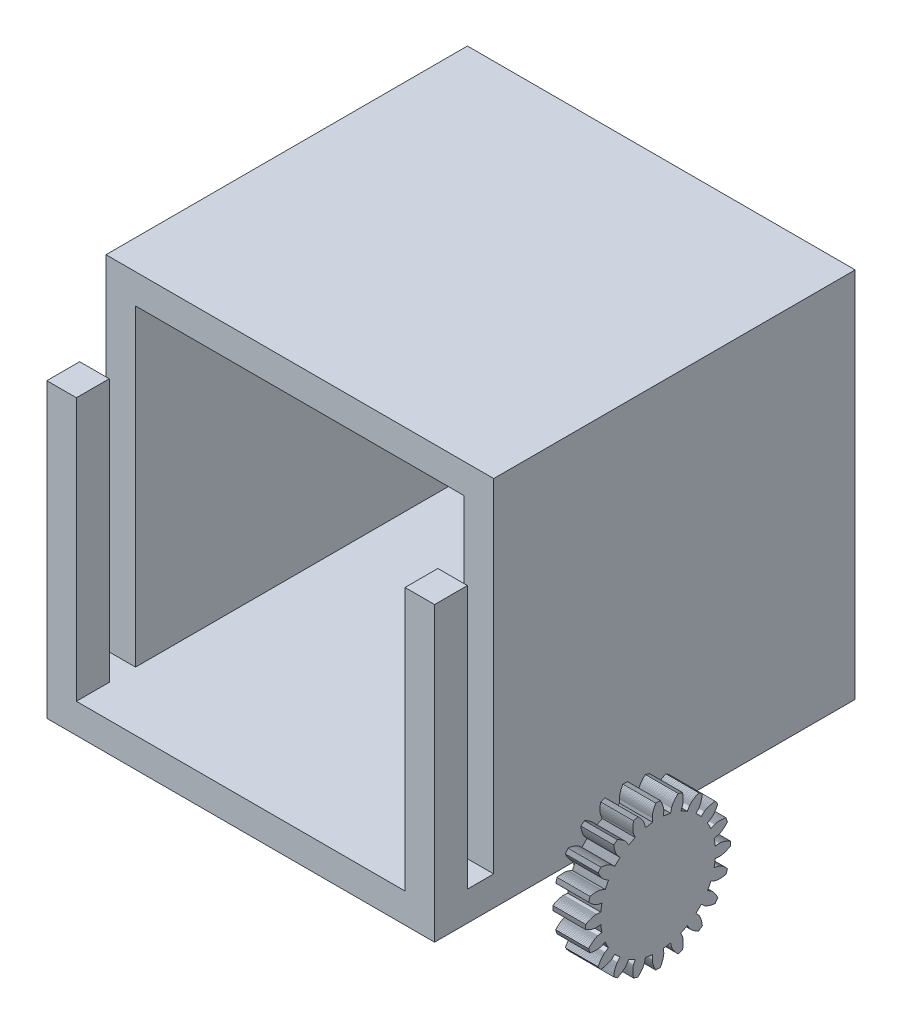
from build123d import *

# Parameters (mm, degrees)
SKETCH1_W           = 59
SKETCH1_H           = 56.6
SKETCH1_W_2         = 50
SKETCH1_H_2         = 47.6
BOSS_EXTRUDE1_DEPTH = 3
BOSS_EXTRUDE2_START = 3
SKETCH1_3_W         = 59
SKETCH1_3_H         = 56.6
SKETCH1_3_W_2       = 50
SKETCH1_3_H_2       = 47.6
BOSS_EXTRUDE2_DEPTH = 52
SKETCH2_W           = 59
SKETCH2_H           = 4.5
BOSS_EXTRUDE3_DEPTH = 4
BOSS_EXTRUDE4_DEPTH = 5
SKETCH4_R           = 1.75
BOSS_EXTRUDE5_DEPTH = 10
BOSS_EXTRUDE6_DEPTH = 5
BOSS_EXTRUDE8_START = 35
BOSS_EXTRUDE8_DEPTH = 3


with BuildPart() as part:
    # Sketch1 → Boss-Extrude1 (new body)
    with BuildSketch(Plane.XY):
        Rectangle(SKETCH1_W, SKETCH1_H)
        Rectangle(SKETCH1_W_2, SKETCH1_H_2, mode=Mode.SUBTRACT)
        Rectangle(SKETCH1_W_2, SKETCH1_H_2)
    extrude(amount=BOSS_EXTRUDE1_DEPTH)

    # Sketch1_3 → Boss-Extrude2 (add)
    with BuildSketch(Plane.XY.offset(BOSS_EXTRUDE2_START)):
        Rectangle(SKETCH1_3_W, SKETCH1_3_H)
        Rectangle(SKETCH1_3_W_2, SKETCH1_3_H_2, mode=Mode.SUBTRACT)
    extrude(amount=BOSS_EXTRUDE2_DEPTH)

    # Sketch2 → Boss-Extrude3 (add)
    with BuildSketch(Plane.XY.offset(55)):
        with Locations((0, -26.05)):
            Rectangle(SKETCH2_W, SKETCH2_H)
    extrude(amount=BOSS_EXTRUDE3_DEPTH)

    # Sketch3 → Boss-Extrude4 (add)
    with BuildSketch(Plane.XY.offset(59)):
        Polygon((-29.5, -28.3), (-29.5, 16.2), (-25, 16.2), (-25, -23.8), (25, -23.8), (25, 16.2), (29.5, 16.2), (29.5, -28.3), align=None)
    extrude(amount=BOSS_EXTRUDE4_DEPTH)

    # Sketch4 → Boss-Extrude5 (add, symmetric)
    with BuildSketch(Plane(origin=(0, -28.3, 0), x_dir=(0, -1, 0), z_dir=(-1, 0, 0))):
        with BuildLine():
            Line((1.895041041, 41.1411879), (6.249518351, 39.416071279))
            ThreePointArc((6.249518351, 39.416071279), (9.25, 35), (6.249518351, 30.583928721))
            Line((6.249518351, 30.583928721), (1.895041041, 28.8588121))
            ThreePointArc((1.895041041, 28.8588121), (0.518581366, 27.755704237), (0, 26.06971445))
            Line((0, 26.06971445), (0, 43.93028555))
            ThreePointArc((0, 43.93028555), (0.518581366, 42.244295763), (1.895041041, 41.1411879))
        make_face()
        with Locations((4.5, 35)):
            Circle(SKETCH4_R, mode=Mode.SUBTRACT)
    extrude(amount=BOSS_EXTRUDE5_DEPTH, both=True)

    # Sketch6 → Boss-Extrude6 (add)
    with BuildSketch(Plane(origin=(29.5, 0, 0), x_dir=(0, 0, -1), z_dir=(1, 0, 0))):
        Polygon((-26.2881519, -33.6164474), (-25.6440481, -33.6768109), (-25.6392413, -33.6771581), (-25.6247974, -33.6777886), (-25.6007031, -33.6780851), (-25.5669749, -33.6774303), (-25.5236589, -33.6752074), (-25.4708308, -33.6708025), (-25.4085958, -33.6636047), (-25.3370884, -33.6530082), (-25.2564722, -33.6384133), (-25.1669396, -33.6192276), (-25.0687116, -33.594867), (-24.9620375, -33.5647573), (-24.8471942, -33.5283355), (-24.7244859, -33.4850503), (-24.5942437, -33.434364), (-24.4568251, -33.3757533), (-24.3126129, -33.3087105), (-24.1620153, -33.2327446), (-24.0054646, -33.1473822), (-24.0043704, -33.110826), (-24.0033977, -33.0742663), (-24.0025466, -33.0377036), (-24.0018171, -33.0011383), (-24.0012091, -32.9645707), (-24.0007228, -32.9280013), (-24.000358, -32.8914305), (-24.0001148, -32.8548587), (-23.999949202, -32.805053205), (-23.999949202, -32.794946795), (-24.0001148, -32.7451413), (-24.000358, -32.7085695), (-24.0007228, -32.6719987), (-24.0012091, -32.6354293), (-24.0018171, -32.5988617), (-24.0025466, -32.5622964), (-24.0033977, -32.5257337), (-24.0043704, -32.489174), (-24.0054646, -32.4526178), (-24.1620153, -32.3672554), (-24.3126129, -32.2912895), (-24.4568251, -32.2242467), (-24.5942437, -32.165636), (-24.7244859, -32.1149497), (-24.8471942, -32.0716645), (-24.9620375, -32.0352427), (-25.0687116, -32.005133), (-25.1669396, -31.9807724), (-25.2564722, -31.9615867), (-25.3370884, -31.9469918), (-25.4085958, -31.9363953), (-25.4708308, -31.9291975), (-25.5236589, -31.9247926), (-25.5669749, -31.9225697), (-25.6007031, -31.9219149), (-25.6247974, -31.9222114), (-25.6392413, -31.9228419), (-25.6440481, -31.9231891), (-26.2881519, -31.9835526), (-26.2938163, -31.9252155), (-26.2998713, -31.8669176), (-26.3063166, -31.8086616), (-26.3131521, -31.7504501), (-26.3203773, -31.6922857), (-26.3279919, -31.634171), (-26.3359957, -31.5761085), (-26.3443882, -31.518101), (-26.3531691, -31.460151), (-26.3623379, -31.4022612), (-26.3718943, -31.344434), (-26.3818379, -31.2866722), (-26.3921681, -31.2289782), (-26.4028846, -31.1713548), (-26.4139868, -31.1138044), (-26.4254743, -31.0563297), (-26.4373465, -30.9989332), (-26.4496029, -30.9416176), (-26.4622429, -30.8843853), (-25.8310104, -30.7427554), (-25.8263316, -30.7416002), (-25.8123998, -30.7377364), (-25.7893931, -30.7305729), (-25.7575181, -30.7195275), (-25.717009, -30.7040281), (-25.6681277, -30.6835139), (-25.611163, -30.6574368), (-25.5464299, -30.6252619), (-25.4742693, -30.5864696), (-25.3950475, -30.5405557), (-25.309155, -30.4870333), (-25.2170063, -30.4254332), (-25.1190387, -30.3553054), (-25.0157121, -30.2762198), (-24.9075074, -30.1877673), (-24.7949261, -30.0895605), (-24.6784896, -29.981235), (-24.5587375, -29.8624499), (-24.4362273, -29.7328886), (-24.4464832, -29.6977835), (-24.4568557, -29.6627126), (-24.4673448, -29.6276764), (-24.4779503, -29.5926752), (-24.4886721, -29.5577095), (-24.4995101, -29.5227797), (-24.5104641, -29.4878861), (-24.5215341, -29.4530291), (-24.53272, -29.4182091), (-24.5440216, -29.3834264), (-24.5554387, -29.3486816), (-24.5669713, -29.3139749), (-24.5786192, -29.2793067), (-24.5903823, -29.2446775), (-24.6022605, -29.2100875), (-24.6142537, -29.1755373), (-24.6263616, -29.1410271), (-24.6385842, -29.1065573), (-24.6509214, -29.0721284), (-24.8261883, -29.0393208), (-24.99289, -29.0136101), (-25.1507612, -28.9944126), (-25.2995659, -28.9811353), (-25.4390964, -28.9731768), (-25.5691748, -28.9699291), (-25.6896523, -28.9707784), (-25.8004098, -28.9751065), (-25.901358, -28.9822923), (-25.9924373, -28.9917126), (-26.0736179, -29.0027439), (-26.1449, -29.0147631), (-26.2063133, -29.0271492), (-26.257917, -29.0392846), (-26.2997998, -29.050556), (-26.3320796, -29.0603557), (-26.354903, -29.0680833), (-26.3684451, -29.0731464), (-26.3729094, -29.0749619), (-26.9668351, -29.3314101), (-26.9902494, -29.2776786), (-27.0140231, -29.2241051), (-27.0381551, -29.1706921), (-27.0626443, -29.1174419), (-27.0874897, -29.0643569), (-27.1126901, -29.0114396), (-27.1382444, -28.9586923), (-27.1641515, -28.9061173), (-27.1904101, -28.853717), (-27.2170192, -28.8014938), (-27.2439774, -28.74945), (-27.2712837, -28.697588), (-27.2989368, -28.64591), (-27.3269354, -28.5944184), (-27.3552782, -28.5431155), (-27.3839641, -28.4920036), (-27.4129917, -28.441085), (-27.4423598, -28.390362), (-27.4720669, -28.3398369), (-26.9154952, -28.0100773), (-26.9114024, -28.0075328), (-26.8993464, -27.999553), (-26.8796794, -27.9856306), (-26.8527776, -27.9652759), (-26.8190408, -27.9380171), (-26.7788912, -27.9034018), (-26.7327728, -27.8609979), (-26.6811505, -27.8103941), (-26.6245092, -27.7512016), (-26.5633529, -27.6830541), (-26.4982037, -27.605609), (-26.4296005, -27.5185483), (-26.3580985, -27.4215792), (-26.2842678, -27.3144346), (-26.2086923, -27.1968741), (-26.1319688, -27.0686844), (-26.0547055, -26.9296799), (-25.9775211, -26.7797031), (-25.9010436, -26.6186253), (-25.9216456, -26.5884075), (-25.942348, -26.5582584), (-25.9631504, -26.5281783), (-25.9840528, -26.4981675), (-26.0050548, -26.4682264), (-26.0261563, -26.4383552), (-26.047357, -26.4085544), (-26.0686566, -26.3788243), (-26.0900549, -26.3491651), (-26.1115518, -26.3195772), (-26.1331469, -26.290061), (-26.15484, -26.2606167), (-26.1766309, -26.2312447), (-26.1985193, -26.2019454), (-26.220505, -26.1727189), (-26.2425878, -26.1435658), (-26.2647674, -26.1144862), (-26.2870435, -26.0854805), (-26.3094159, -26.056549), (-26.4862428, -26.0795076), (-26.6527305, -26.1065689), (-26.8088074, -26.137096), (-26.9544319, -26.1704516), (-27.0895927, -26.206), (-27.2143082, -26.2431076), (-27.3286266, -26.2811449), (-27.4326258, -26.3194872), (-27.5264127, -26.357516), (-27.6101232, -26.3946203), (-27.6839218, -26.4301979), (-27.7480009, -26.4636562), (-27.8025809, -26.4944138), (-27.8479089, -26.5219017), (-27.8842588, -26.5455639), (-27.9119304, -26.564859), (-27.9312487, -26.5792612), (-27.9425635, -26.5882612), (-27.9462482, -26.5913674), (-28.4318584, -27.0187973), (-28.4707306, -26.974931), (-28.5098958, -26.9313261), (-28.5493523, -26.8879845), (-28.5890981, -26.8449081), (-28.6291316, -26.802099), (-28.669451, -26.759559), (-28.7100544, -26.71729), (-28.7509401, -26.6752939), (-28.7921061, -26.6335727), (-28.8335507, -26.5921281), (-28.8752719, -26.5509621), (-28.917268, -26.5100764), (-28.959537, -26.469473), (-29.002077, -26.4291536), (-29.0448861, -26.3891201), (-29.0879625, -26.3493743), (-29.1313041, -26.3099178), (-29.174909, -26.2707526), (-29.2187753, -26.2318804), (-28.7913454, -25.7462702), (-28.7882392, -25.7425855), (-28.7792392, -25.7312707), (-28.764837, -25.7119524), (-28.7455419, -25.6842808), (-28.7218797, -25.6479309), (-28.6943918, -25.6026029), (-28.6636342, -25.5480229), (-28.6301759, -25.4839438), (-28.5945983, -25.4101452), (-28.557494, -25.3264347), (-28.5194652, -25.2326478), (-28.4811229, -25.1286486), (-28.4430856, -25.0143302), (-28.405978, -24.8896147), (-28.3704296, -24.7544539), (-28.337074, -24.6088294), (-28.3065469, -24.4527525), (-28.2794856, -24.2862648), (-28.256527, -24.1094379), (-28.2854585, -24.0870655), (-28.3144642, -24.0647894), (-28.3435438, -24.0426098), (-28.3726969, -24.020527), (-28.4019234, -23.9985413), (-28.4312227, -23.9766529), (-28.4605947, -23.954862), (-28.490039, -23.9331689), (-28.5195552, -23.9115738), (-28.5491431, -23.8900769), (-28.5788023, -23.8686786), (-28.6085324, -23.847379), (-28.6383332, -23.8261783), (-28.6682044, -23.8050768), (-28.6981455, -23.7840748), (-28.7281563, -23.7631724), (-28.7582364, -23.74237), (-28.7883855, -23.7216676), (-28.8186033, -23.7010656), (-28.9796811, -23.7775431), (-29.1296579, -23.8547275), (-29.2686624, -23.9319908), (-29.3968521, -24.0087143), (-29.5144126, -24.0842898), (-29.6215572, -24.1581205), (-29.7185263, -24.2296225), (-29.805587, -24.2982257), (-29.8830321, -24.3633749), (-29.9511796, -24.4245312), (-30.0103721, -24.4811725), (-30.0609759, -24.5327948), (-30.1033798, -24.5789132), (-30.1379951, -24.6190628), (-30.1652539, -24.6527996), (-30.1856086, -24.6797014), (-30.199531, -24.6993684), (-30.2075108, -24.7114244), (-30.2100553, -24.7155172), (-30.5398149, -25.2720889), (-30.59034, -25.2423818), (-30.641063, -25.2130137), (-30.6919816, -25.1839861), (-30.7430935, -25.1553002), (-30.7943964, -25.1269574), (-30.845888, -25.0989588), (-30.897566, -25.0713057), (-30.949428, -25.0439994), (-31.0014718, -25.0170412), (-31.053695, -24.9904321), (-31.1060953, -24.9641735), (-31.1586703, -24.9382664), (-31.2114176, -24.9127121), (-31.2643349, -24.8875117), (-31.3174199, -24.8626663), (-31.3706701, -24.8381771), (-31.4240831, -24.8140451), (-31.4776566, -24.7902714), (-31.5313881, -24.7668571), (-31.2749399, -24.1729314), (-31.2731244, -24.1684671), (-31.2680613, -24.154925), (-31.2603337, -24.1321016), (-31.250534, -24.0998218), (-31.2392626, -24.057939), (-31.2271272, -24.0063353), (-31.2147411, -23.944922), (-31.2027219, -23.8736399), (-31.1916906, -23.7924593), (-31.1822703, -23.70138), (-31.1750845, -23.6004318), (-31.1707564, -23.4896743), (-31.1699071, -23.3691968), (-31.1731548, -23.2391184), (-31.1811133, -23.0995879), (-31.1943906, -22.9507832), (-31.2135881, -22.792912), (-31.2392988, -22.6262103), (-31.2721064, -22.4509434), (-31.3065353, -22.4386062), (-31.3410051, -22.4263836), (-31.3755153, -22.4142757), (-31.4100655, -22.4022825), (-31.4446555, -22.3904043), (-31.4792847, -22.3786412), (-31.5139529, -22.3669933), (-31.5486596, -22.3554607), (-31.5834044, -22.3440436), (-31.6181871, -22.332742), (-31.6530071, -22.3215561), (-31.6878641, -22.3104861), (-31.7227577, -22.2995321), (-31.7576875, -22.2886941), (-31.7926532, -22.2779723), (-31.8276544, -22.2673668), (-31.8626906, -22.2568777), (-31.8977615, -22.2465052), (-31.9328666, -22.2362493), (-32.0624279, -22.3587595), (-32.181213, -22.4785116), (-32.2895385, -22.5949481), (-32.3877453, -22.7075294), (-32.4761978, -22.8157341), (-32.5552834, -22.9190607), (-32.6254112, -23.0170283), (-32.6870113, -23.109177), (-32.7405337, -23.1950695), (-32.7864476, -23.2742913), (-32.8252399, -23.3464519), (-32.8574148, -23.411185), (-32.8834919, -23.4681497), (-32.9040061, -23.517031), (-32.9195055, -23.5575401), (-32.9305509, -23.5894151), (-32.9377144, -23.6124218), (-32.9415782, -23.6263536), (-32.9427334, -23.6310324), (-33.0843633, -24.2622649), (-33.1415956, -24.2496249), (-33.1989112, -24.2373685), (-33.2563077, -24.2254963), (-33.3137824, -24.2140088), (-33.3713328, -24.2029066), (-33.4289562, -24.1921901), (-33.4866502, -24.1818599), (-33.544412, -24.1719163), (-33.6022392, -24.1623599), (-33.660129, -24.1531911), (-33.718079, -24.1444102), (-33.7760865, -24.1360177), (-33.834149, -24.1280139), (-33.8922637, -24.1203993), (-33.9504281, -24.1131741), (-34.0086396, -24.1063386), (-34.0668956, -24.0998933), (-34.1251935, -24.0938383), (-34.1835306, -24.0881739), (-34.1231671, -23.4440701), (-34.1228199, -23.4392633), (-34.1221894, -23.4248194), (-34.1218929, -23.4007251), (-34.1225477, -23.3669969), (-34.1247706, -23.3236809), (-34.1291755, -23.2708528), (-34.1363733, -23.2086178), (-34.1469698, -23.1371104), (-34.1615647, -23.0564942), (-34.1807504, -22.9669616), (-34.205111, -22.8687336), (-34.2352207, -22.7620595), (-34.2716425, -22.6472162), (-34.3149277, -22.5245079), (-34.365614, -22.3942657), (-34.4242247, -22.2568471), (-34.4912675, -22.1126349), (-34.5672334, -21.9620373), (-34.6525958, -21.8054866), (-34.689152, -21.8043924), (-34.7257117, -21.8034197), (-34.7622744, -21.8025686), (-34.7988397, -21.8018391), (-34.8354073, -21.8012311), (-34.8719767, -21.8007448), (-34.9085475, -21.80038), (-34.9451193, -21.8001368), (-34.9816917, -21.8000152), (-35.0182643, -21.8000152), (-35.0548367, -21.8001368), (-35.0914085, -21.80038), (-35.1279793, -21.8007448), (-35.1645487, -21.8012311), (-35.2011163, -21.8018391), (-35.2376816, -21.8025686), (-35.2742443, -21.8034197), (-35.310804, -21.8043924), (-35.3473602, -21.8054866), (-35.4327226, -21.9620373), (-35.5086885, -22.1126349), (-35.5757313, -22.2568471), (-35.634342, -22.3942657), (-35.6850283, -22.5245079), (-35.7283135, -22.6472162), (-35.7647353, -22.7620595), (-35.794845, -22.8687336), (-35.8192056, -22.9669616), (-35.8383913, -23.0564942), (-35.8529862, -23.1371104), (-35.8635827, -23.2086178), (-35.8707805, -23.2708528), (-35.8751854, -23.3236809), (-35.8774083, -23.3669969), (-35.8780631, -23.4007251), (-35.8777666, -23.4248194), (-35.8771361, -23.4392633), (-35.8767889, -23.4440701), (-35.8164254, -24.0881739), (-35.8747625, -24.0938383), (-35.9330604, -24.0998933), (-35.9913164, -24.1063386), (-36.0495279, -24.1131741), (-36.1076923, -24.1203993), (-36.165807, -24.1280139), (-36.2238695, -24.1360177), (-36.281877, -24.1444102), (-36.339827, -24.1531911), (-36.3977168, -24.1623599), (-36.455544, -24.1719163), (-36.5133058, -24.1818599), (-36.5709998, -24.1921901), (-36.6286232, -24.2029066), (-36.6861736, -24.2140088), (-36.7436483, -24.2254963), (-36.8010448, -24.2373685), (-36.8583604, -24.2496249), (-36.9155927, -24.2622649), (-37.0572226, -23.6310324), (-37.0583778, -23.6263536), (-37.0622416, -23.6124218), (-37.0694051, -23.5894151), (-37.0804505, -23.5575401), (-37.0959499, -23.517031), (-37.1164641, -23.4681497), (-37.1425412, -23.411185), (-37.1747161, -23.3464519), (-37.2135084, -23.2742913), (-37.2594223, -23.1950695), (-37.3129447, -23.109177), (-37.3745448, -23.0170283), (-37.4446726, -22.9190607), (-37.5237582, -22.8157341), (-37.6122107, -22.7075294), (-37.7104175, -22.5949481), (-37.818743, -22.4785116), (-37.9375281, -22.3587595), (-38.0670894, -22.2362493), (-38.1021945, -22.2465052), (-38.1372654, -22.2568777), (-38.1723016, -22.2673668), (-38.2073028, -22.2779723), (-38.2422685, -22.2886941), (-38.2771983, -22.2995321), (-38.3120919, -22.3104861), (-38.3469489, -22.3215561), (-38.3817689, -22.332742), (-38.4165516, -22.3440436), (-38.4512964, -22.3554607), (-38.4860031, -22.3669933), (-38.5206713, -22.3786412), (-38.5553005, -22.3904043), (-38.5898905, -22.4022825), (-38.6244407, -22.4142757), (-38.6589509, -22.4263836), (-38.6934207, -22.4386062), (-38.7278496, -22.4509434), (-38.7606572, -22.6262103), (-38.7863679, -22.792912), (-38.8055654, -22.9507832), (-38.8188427, -23.0995879), (-38.8268012, -23.2391184), (-38.8300489, -23.3691968), (-38.8291996, -23.4896743), (-38.8248715, -23.6004318), (-38.8176857, -23.70138), (-38.8082654, -23.7924593), (-38.7972341, -23.8736399), (-38.7852149, -23.944922), (-38.7728288, -24.0063353), (-38.7606934, -24.057939), (-38.749422, -24.0998218), (-38.7396223, -24.1321016), (-38.7318947, -24.154925), (-38.7268316, -24.1684671), (-38.7250161, -24.1729314), (-38.4685679, -24.7668571), (-38.5222994, -24.7902714), (-38.5758729, -24.8140451), (-38.6292859, -24.8381771), (-38.6825361, -24.8626663), (-38.7356211, -24.8875117), (-38.7885384, -24.9127121), (-38.8412857, -24.9382664), (-38.8938607, -24.9641735), (-38.946261, -24.9904321), (-38.9984842, -25.0170412), (-39.050528, -25.0439994), (-39.10239, -25.0713057), (-39.154068, -25.0989588), (-39.2055596, -25.1269574), (-39.2568625, -25.1553002), (-39.3079744, -25.1839861), (-39.358893, -25.2130137), (-39.409616, -25.2423818), (-39.4601411, -25.2720889), (-39.7899007, -24.7155172), (-39.7924452, -24.7114244), (-39.800425, -24.6993684), (-39.8143474, -24.6797014), (-39.8347021, -24.6527996), (-39.8619609, -24.6190628), (-39.8965762, -24.5789132), (-39.9389801, -24.5327948), (-39.9895839, -24.4811725), (-40.0487764, -24.4245312), (-40.1169239, -24.3633749), (-40.194369, -24.2982257), (-40.2814297, -24.2296225), (-40.3783988, -24.1581205), (-40.4855434, -24.0842898), (-40.6031039, -24.0087143), (-40.7312936, -23.9319908), (-40.8702981, -23.8547275), (-41.0202749, -23.7775431), (-41.1813527, -23.7010656), (-41.2115705, -23.7216676), (-41.2417196, -23.74237), (-41.2717997, -23.7631724), (-41.3018105, -23.7840748), (-41.3317516, -23.8050768), (-41.3616228, -23.8261783), (-41.3914236, -23.847379), (-41.4211537, -23.8686786), (-41.4508129, -23.8900769), (-41.4804008, -23.9115738), (-41.509917, -23.9331689), (-41.5393613, -23.954862), (-41.5687333, -23.9766529), (-41.5980326, -23.9985413), (-41.6272591, -24.020527), (-41.6564122, -24.0426098), (-41.6854918, -24.0647894), (-41.7144975, -24.0870655), (-41.743429, -24.1094379), (-41.7204704, -24.2862648), (-41.6934091, -24.4527525), (-41.662882, -24.6088294), (-41.6295264, -24.7544539), (-41.593978, -24.8896147), (-41.5568704, -25.0143302), (-41.5188331, -25.1286486), (-41.4804908, -25.2326478), (-41.442462, -25.3264347), (-41.4053577, -25.4101452), (-41.3697801, -25.4839438), (-41.3363218, -25.5480229), (-41.3055642, -25.6026029), (-41.2780763, -25.6479309), (-41.2544141, -25.6842808), (-41.235119, -25.7119524), (-41.2207168, -25.7312707), (-41.2117168, -25.7425855), (-41.2086106, -25.7462702), (-40.7811807, -26.2318804), (-40.825047, -26.2707526), (-40.8686519, -26.3099178), (-40.9119935, -26.3493743), (-40.9550699, -26.3891201), (-40.997879, -26.4291536), (-41.040419, -26.469473), (-41.082688, -26.5100764), (-41.1246841, -26.5509621), (-41.1664053, -26.5921281), (-41.2078499, -26.6335727), (-41.2490159, -26.6752939), (-41.2899016, -26.71729), (-41.330505, -26.759559), (-41.3708244, -26.802099), (-41.4108579, -26.8449081), (-41.4506037, -26.8879845), (-41.4900602, -26.9313261), (-41.5292254, -26.974931), (-41.5680976, -27.0187973), (-42.0537078, -26.5913674), (-42.0573925, -26.5882612), (-42.0687073, -26.5792612), (-42.0880256, -26.564859), (-42.1156972, -26.5455639), (-42.1520471, -26.5219017), (-42.1973751, -26.4944138), (-42.2519551, -26.4636562), (-42.3160342, -26.4301979), (-42.3898328, -26.3946203), (-42.4735433, -26.357516), (-42.5673302, -26.3194872), (-42.6713294, -26.2811449), (-42.7856478, -26.2431076), (-42.9103633, -26.206), (-43.0455241, -26.1704516), (-43.1911486, -26.137096), (-43.3472255, -26.1065689), (-43.5137132, -26.0795076), (-43.6905401, -26.056549), (-43.7129125, -26.0854805), (-43.7351886, -26.1144862), (-43.7573682, -26.1435658), (-43.779451, -26.1727189), (-43.8014367, -26.2019454), (-43.8233251, -26.2312447), (-43.845116, -26.2606167), (-43.8668091, -26.290061), (-43.8884042, -26.3195772), (-43.9099011, -26.3491651), (-43.9312994, -26.3788243), (-43.952599, -26.4085544), (-43.9737997, -26.4383552), (-43.9949012, -26.4682264), (-44.0159032, -26.4981675), (-44.0368056, -26.5281783), (-44.057608, -26.5582584), (-44.0783104, -26.5884075), (-44.0989124, -26.6186253), (-44.0224349, -26.7797031), (-43.9452505, -26.9296799), (-43.8679872, -27.0686844), (-43.7912637, -27.1968741), (-43.7156882, -27.3144346), (-43.6418575, -27.4215792), (-43.5703555, -27.5185483), (-43.5017523, -27.605609), (-43.4366031, -27.6830541), (-43.3754468, -27.7512016), (-43.3188055, -27.8103941), (-43.2671832, -27.8609979), (-43.2210648, -27.9034018), (-43.1809152, -27.9380171), (-43.1471784, -27.9652759), (-43.1202766, -27.9856306), (-43.1006096, -27.999553), (-43.0885536, -28.0075328), (-43.0844608, -28.0100773), (-42.5278891, -28.3398369), (-42.5575962, -28.390362), (-42.5869643, -28.441085), (-42.6159919, -28.4920036), (-42.6446778, -28.5431155), (-42.6730206, -28.5944184), (-42.7010192, -28.64591), (-42.7286723, -28.697588), (-42.7559786, -28.74945), (-42.7829368, -28.8014938), (-42.8095459, -28.853717), (-42.8358045, -28.9061173), (-42.8617116, -28.9586923), (-42.8872659, -29.0114396), (-42.9124663, -29.0643569), (-42.9373117, -29.1174419), (-42.9618009, -29.1706921), (-42.9859329, -29.2241051), (-43.0097066, -29.2776786), (-43.0331209, -29.3314101), (-43.6270466, -29.0749619), (-43.6315109, -29.0731464), (-43.645053, -29.0680833), (-43.6678764, -29.0603557), (-43.7001562, -29.050556), (-43.742039, -29.0392846), (-43.7936427, -29.0271492), (-43.855056, -29.0147631), (-43.9263381, -29.0027439), (-44.0075187, -28.9917126), (-44.098598, -28.9822923), (-44.1995462, -28.9751065), (-44.3103037, -28.9707784), (-44.4307812, -28.9699291), (-44.5608596, -28.9731768), (-44.7003901, -28.9811353), (-44.8491948, -28.9944126), (-45.007066, -29.0136101), (-45.1737677, -29.0393208), (-45.3490346, -29.0721284), (-45.3613718, -29.1065573), (-45.3735944, -29.1410271), (-45.3857023, -29.1755373), (-45.3976955, -29.2100875), (-45.4095737, -29.2446775), (-45.4213368, -29.2793067), (-45.4329847, -29.3139749), (-45.4445173, -29.3486816), (-45.4559344, -29.3834264), (-45.467236, -29.4182091), (-45.4784219, -29.4530291), (-45.4894919, -29.4878861), (-45.5004459, -29.5227797), (-45.5112839, -29.5577095), (-45.5220057, -29.5926752), (-45.5326112, -29.6276764), (-45.5431003, -29.6627126), (-45.5534728, -29.6977835), (-45.5637287, -29.7328886), (-45.4412185, -29.8624499), (-45.3214664, -29.981235), (-45.2050299, -30.0895605), (-45.0924486, -30.1877673), (-44.9842439, -30.2762198), (-44.8809173, -30.3553054), (-44.7829497, -30.4254332), (-44.690801, -30.4870333), (-44.6049085, -30.5405557), (-44.5256867, -30.5864696), (-44.4535261, -30.6252619), (-44.388793, -30.6574368), (-44.3318283, -30.6835139), (-44.282947, -30.7040281), (-44.2424379, -30.7195275), (-44.2105629, -30.7305729), (-44.1875562, -30.7377364), (-44.1736244, -30.7416002), (-44.1689456, -30.7427554), (-43.5377131, -30.8843853), (-43.5503531, -30.9416176), (-43.5626095, -30.9989332), (-43.5744817, -31.0563297), (-43.5859692, -31.1138044), (-43.5970714, -31.1713548), (-43.6077879, -31.2289782), (-43.6181181, -31.2866722), (-43.6280617, -31.344434), (-43.6376181, -31.4022612), (-43.6467869, -31.460151), (-43.6555678, -31.518101), (-43.6639603, -31.5761085), (-43.6719641, -31.634171), (-43.6795787, -31.6922857), (-43.6868039, -31.7504501), (-43.6936394, -31.8086616), (-43.7000847, -31.8669176), (-43.7061397, -31.9252155), (-43.7118041, -31.9835526), (-44.3559079, -31.9231891), (-44.3607147, -31.9228419), (-44.3751586, -31.9222114), (-44.3992529, -31.9219149), (-44.4329811, -31.9225697), (-44.4762971, -31.9247926), (-44.5291252, -31.9291975), (-44.5913602, -31.9363953), (-44.6628676, -31.9469918), (-44.7434838, -31.9615867), (-44.8330164, -31.9807724), (-44.9312444, -32.005133), (-45.0379185, -32.0352427), (-45.1527618, -32.0716645), (-45.2754701, -32.1149497), (-45.4057123, -32.165636), (-45.5431309, -32.2242467), (-45.6873431, -32.2912895), (-45.8379407, -32.3672554), (-45.9944914, -32.4526178), (-45.9955856, -32.489174), (-45.9965583, -32.5257337), (-45.9974094, -32.5622964), (-45.9981389, -32.5988617), (-45.9987469, -32.6354293), (-45.9992332, -32.6719987), (-45.999598, -32.7085695), (-45.9998412, -32.7451413), (-45.9999628, -32.7817137), (-45.9999628, -32.8182863), (-45.9998412, -32.8548587), (-45.999598, -32.8914305), (-45.9992332, -32.9280013), (-45.9987469, -32.9645707), (-45.9981389, -33.0011383), (-45.9974094, -33.0377036), (-45.9965583, -33.0742663), (-45.9955856, -33.110826), (-45.9944914, -33.1473822), (-45.8379407, -33.2327446), (-45.6873431, -33.3087105), (-45.5431309, -33.3757533), (-45.4057123, -33.434364), (-45.2754701, -33.4850503), (-45.1527618, -33.5283355), (-45.0379185, -33.5647573), (-44.9312444, -33.594867), (-44.8330164, -33.6192276), (-44.7434838, -33.6384133), (-44.6628676, -33.6530082), (-44.5913602, -33.6636047), (-44.5291252, -33.6708025), (-44.4762971, -33.6752074), (-44.4329811, -33.6774303), (-44.3992529, -33.6780851), (-44.3751586, -33.6777886), (-44.3607147, -33.6771581), (-44.3559079, -33.6768109), (-43.7118041, -33.6164474), (-43.7061397, -33.6747845), (-43.7000847, -33.7330824), (-43.6936394, -33.7913384), (-43.6868039, -33.8495499), (-43.6795787, -33.9077143), (-43.6719641, -33.965829), (-43.6639603, -34.0238915), (-43.6555678, -34.081899), (-43.6467869, -34.139849), (-43.6376181, -34.1977388), (-43.6280617, -34.255566), (-43.6181181, -34.3133278), (-43.6077879, -34.3710218), (-43.5970714, -34.4286452), (-43.5859692, -34.4861956), (-43.5744817, -34.5436703), (-43.5626095, -34.6010668), (-43.5503531, -34.6583824), (-43.5377131, -34.7156147), (-44.1689456, -34.8572446), (-44.1736244, -34.8583998), (-44.1875562, -34.8622636), (-44.2105629, -34.8694271), (-44.2424379, -34.8804725), (-44.282947, -34.8959719), (-44.3318283, -34.9164861), (-44.388793, -34.9425632), (-44.4535261, -34.9747381), (-44.5256867, -35.0135304), (-44.6049085, -35.0594443), (-44.690801, -35.1129667), (-44.7829497, -35.1745668), (-44.8809173, -35.2446946), (-44.9842439, -35.3237802), (-45.0924486, -35.4122327), (-45.2050299, -35.5104395), (-45.3214664, -35.618765), (-45.4412185, -35.7375501), (-45.5637287, -35.8671114), (-45.5534728, -35.9022165), (-45.5431003, -35.9372874), (-45.5326112, -35.9723236), (-45.5220057, -36.0073248), (-45.5112839, -36.0422905), (-45.5004459, -36.0772203), (-45.4894919, -36.1121139), (-45.4784219, -36.1469709), (-45.467236, -36.1817909), (-45.4559344, -36.2165736), (-45.4445173, -36.2513184), (-45.4329847, -36.2860251), (-45.4213368, -36.3206933), (-45.4095737, -36.3553225), (-45.3976955, -36.3899125), (-45.3857023, -36.4244627), (-45.3735944, -36.4589729), (-45.3613718, -36.4934427), (-45.3490346, -36.5278716), (-45.1737677, -36.5606792), (-45.007066, -36.5863899), (-44.8491948, -36.6055874), (-44.7003901, -36.6188647), (-44.5608596, -36.6268232), (-44.4307812, -36.6300709), (-44.3103037, -36.6292216), (-44.1995462, -36.6248935), (-44.098598, -36.6177077), (-44.0075187, -36.6082874), (-43.9263381, -36.5972561), (-43.855056, -36.5852369), (-43.7936427, -36.5728508), (-43.742039, -36.5607154), (-43.7001562, -36.549444), (-43.6678764, -36.5396443), (-43.645053, -36.5319167), (-43.6315109, -36.5268536), (-43.6270466, -36.5250381), (-43.0331209, -36.2685899), (-43.0097066, -36.3223214), (-42.9859329, -36.3758949), (-42.9618009, -36.4293079), (-42.9373117, -36.4825581), (-42.9124663, -36.5356431), (-42.8872659, -36.5885604), (-42.8617116, -36.6413077), (-42.8358045, -36.6938827), (-42.8095459, -36.746283), (-42.7829368, -36.7985062), (-42.7559786, -36.85055), (-42.7286723, -36.902412), (-42.7010192, -36.95409), (-42.6730206, -37.0055816), (-42.6446778, -37.0568845), (-42.6159919, -37.1079964), (-42.5869643, -37.158915), (-42.5575962, -37.209638), (-42.5278891, -37.2601631), (-43.0844608, -37.5899227), (-43.0885536, -37.5924672), (-43.1006096, -37.600447), (-43.1202766, -37.6143694), (-43.1471784, -37.6347241), (-43.1809152, -37.6619829), (-43.2210648, -37.6965982), (-43.2671832, -37.7390021), (-43.3188055, -37.7896059), (-43.3754468, -37.8487984), (-43.4366031, -37.9169459), (-43.5017523, -37.994391), (-43.5703555, -38.0814517), (-43.6418575, -38.1784208), (-43.7156882, -38.2855654), (-43.7912637, -38.4031259), (-43.8679872, -38.5313156), (-43.9452505, -38.6703201), (-44.0224349, -38.8202969), (-44.0989124, -38.9813747), (-44.0783104, -39.0115925), (-44.057608, -39.0417416), (-44.0368056, -39.0718217), (-44.0159032, -39.1018325), (-43.9949012, -39.1317736), (-43.9737997, -39.1616448), (-43.952599, -39.1914456), (-43.9312994, -39.2211757), (-43.9099011, -39.2508349), (-43.8884042, -39.2804228), (-43.8668091, -39.309939), (-43.845116, -39.3393833), (-43.8233251, -39.3687553), (-43.8014367, -39.3980546), (-43.779451, -39.4272811), (-43.7573682, -39.4564342), (-43.7351886, -39.4855138), (-43.7129125, -39.5145195), (-43.6905401, -39.543451), (-43.5137132, -39.5204924), (-43.3472255, -39.4934311), (-43.1911486, -39.462904), (-43.0455241, -39.4295484), (-42.9103633, -39.394), (-42.7856478, -39.3568924), (-42.6713294, -39.3188551), (-42.5673302, -39.2805128), (-42.4735433, -39.242484), (-42.3898328, -39.2053797), (-42.3160342, -39.1698021), (-42.2519551, -39.1363438), (-42.1973751, -39.1055862), (-42.1520471, -39.0780983), (-42.1156972, -39.0544361), (-42.0880256, -39.035141), (-42.0687073, -39.0207388), (-42.0573925, -39.0117388), (-42.0537078, -39.0086326), (-41.5680976, -38.5812027), (-41.5292254, -38.625069), (-41.4900602, -38.6686739), (-41.4506037, -38.7120155), (-41.4108579, -38.7550919), (-41.3708244, -38.797901), (-41.330505, -38.840441), (-41.2899016, -38.88271), (-41.2490159, -38.9247061), (-41.2078499, -38.9664273), (-41.1664053, -39.0078719), (-41.1246841, -39.0490379), (-41.082688, -39.0899236), (-41.040419, -39.130527), (-40.997879, -39.1708464), (-40.9550699, -39.2108799), (-40.9119935, -39.2506257), (-40.8686519, -39.2900822), (-40.825047, -39.3292474), (-40.7811807, -39.3681196), (-41.2086106, -39.8537298), (-41.2117168, -39.8574145), (-41.2207168, -39.8687293), (-41.235119, -39.8880476), (-41.2544141, -39.9157192), (-41.2780763, -39.9520691), (-41.3055642, -39.9973971), (-41.3363218, -40.0519771), (-41.3697801, -40.1160562), (-41.4053577, -40.1898548), (-41.442462, -40.2735653), (-41.4804908, -40.3673522), (-41.5188331, -40.4713514), (-41.5568704, -40.5856698), (-41.593978, -40.7103853), (-41.6295264, -40.8455461), (-41.662882, -40.9911706), (-41.6934091, -41.1472475), (-41.7204704, -41.3137352), (-41.743429, -41.4905621), (-41.7144975, -41.5129345), (-41.6854918, -41.5352106), (-41.6564122, -41.5573902), (-41.6272591, -41.579473), (-41.5980326, -41.6014587), (-41.5687333, -41.6233471), (-41.5393613, -41.645138), (-41.509917, -41.6668311), (-41.4804008, -41.6884262), (-41.4508129, -41.7099231), (-41.4211537, -41.7313214), (-41.3914236, -41.752621), (-41.3616228, -41.7738217), (-41.3317516, -41.7949232), (-41.3018105, -41.8159252), (-41.2717997, -41.8368276), (-41.2417196, -41.85763), (-41.2115705, -41.8783324), (-41.1813527, -41.8989344), (-41.0202749, -41.8224569), (-40.8702981, -41.7452725), (-40.7312936, -41.6680092), (-40.6031039, -41.5912857), (-40.4855434, -41.5157102), (-40.3783988, -41.4418795), (-40.2814297, -41.3703775), (-40.194369, -41.3017743), (-40.1169239, -41.2366251), (-40.0487764, -41.1754688), (-39.9895839, -41.1188275), (-39.9389801, -41.0672052), (-39.8965762, -41.0210868), (-39.8619609, -40.9809372), (-39.8347021, -40.9472004), (-39.8143474, -40.9202986), (-39.800425, -40.9006316), (-39.7924452, -40.8885756), (-39.7899007, -40.8844828), (-39.4601411, -40.3279111), (-39.409616, -40.3576182), (-39.358893, -40.3869863), (-39.3079744, -40.4160139), (-39.2568625, -40.4446998), (-39.2055596, -40.4730426), (-39.154068, -40.5010412), (-39.10239, -40.5286943), (-39.050528, -40.5560006), (-38.9984842, -40.5829588), (-38.946261, -40.6095679), (-38.8938607, -40.6358265), (-38.8412857, -40.6617336), (-38.7885384, -40.6872879), (-38.7356211, -40.7124883), (-38.6825361, -40.7373337), (-38.6292859, -40.7618229), (-38.5758729, -40.7859549), (-38.5222994, -40.8097286), (-38.4685679, -40.8331429), (-38.7250161, -41.4270686), (-38.7268316, -41.4315329), (-38.7318947, -41.445075), (-38.7396223, -41.4678984), (-38.749422, -41.5001782), (-38.7606934, -41.542061), (-38.7728288, -41.5936647), (-38.7852149, -41.655078), (-38.7972341, -41.7263601), (-38.8082654, -41.8075407), (-38.8176857, -41.89862), (-38.8248715, -41.9995682), (-38.8291996, -42.1103257), (-38.8300489, -42.2308032), (-38.8268012, -42.3608816), (-38.8188427, -42.5004121), (-38.8055654, -42.6492168), (-38.7863679, -42.807088), (-38.7606572, -42.9737897), (-38.7278496, -43.1490566), (-38.6934207, -43.1613938), (-38.6589509, -43.1736164), (-38.6244407, -43.1857243), (-38.5898905, -43.1977175), (-38.5553005, -43.2095957), (-38.5206713, -43.2213588), (-38.4860031, -43.2330067), (-38.4512964, -43.2445393), (-38.4165516, -43.2559564), (-38.3817689, -43.267258), (-38.3469489, -43.2784439), (-38.3120919, -43.2895139), (-38.2771983, -43.3004679), (-38.2422685, -43.3113059), (-38.2073028, -43.3220277), (-38.1723016, -43.3326332), (-38.1372654, -43.3431223), (-38.1021945, -43.3534948), (-38.0670894, -43.3637507), (-37.9375281, -43.2412405), (-37.818743, -43.1214884), (-37.7104175, -43.0050519), (-37.6122107, -42.8924706), (-37.5237582, -42.7842659), (-37.4446726, -42.6809393), (-37.3745448, -42.5829717), (-37.3129447, -42.490823), (-37.2594223, -42.4049305), (-37.2135084, -42.3257087), (-37.1747161, -42.2535481), (-37.1425412, -42.188815), (-37.1164641, -42.1318503), (-37.0959499, -42.082969), (-37.0804505, -42.0424599), (-37.0694051, -42.0105849), (-37.0622416, -41.9875782), (-37.0583778, -41.9736464), (-37.0572226, -41.9689676), (-36.9155927, -41.3377351), (-36.8583604, -41.3503751), (-36.8010448, -41.3626315), (-36.7436483, -41.3745037), (-36.6861736, -41.3859912), (-36.6286232, -41.3970934), (-36.5709998, -41.4078099), (-36.5133058, -41.4181401), (-36.455544, -41.4280837), (-36.3977168, -41.4376401), (-36.339827, -41.4468089), (-36.281877, -41.4555898), (-36.2238695, -41.4639823), (-36.165807, -41.4719861), (-36.1076923, -41.4796007), (-36.0495279, -41.4868259), (-35.9913164, -41.4936614), (-35.9330604, -41.5001067), (-35.8747625, -41.5061617), (-35.8164254, -41.5118261), (-35.8767889, -42.1559299), (-35.8771361, -42.1607367), (-35.8777666, -42.1751806), (-35.8780631, -42.1992749), (-35.8774083, -42.2330031), (-35.8751854, -42.2763191), (-35.8707805, -42.3291472), (-35.8635827, -42.3913822), (-35.8529862, -42.4628896), (-35.8383913, -42.5435058), (-35.8192056, -42.6330384), (-35.794845, -42.7312664), (-35.7647353, -42.8379405), (-35.7283135, -42.9527838), (-35.6850283, -43.0754921), (-35.634342, -43.2057343), (-35.5757313, -43.3431529), (-35.5086885, -43.4873651), (-35.4327226, -43.6379627), (-35.3473602, -43.7945134), (-35.310804, -43.7956076), (-35.2742443, -43.7965803), (-35.2376816, -43.7974314), (-35.2011163, -43.7981609), (-35.1645487, -43.7987689), (-35.1279793, -43.7992552), (-35.0914085, -43.79962), (-35.0548367, -43.7998632), (-35.0182643, -43.7999848), (-34.9816917, -43.7999848), (-34.9451193, -43.7998632), (-34.9085475, -43.79962), (-34.8719767, -43.7992552), (-34.8354073, -43.7987689), (-34.7988397, -43.7981609), (-34.7622744, -43.7974314), (-34.7257117, -43.7965803), (-34.689152, -43.7956076), (-34.6525958, -43.7945134), (-34.5672334, -43.6379627), (-34.4912675, -43.4873651), (-34.4242247, -43.3431529), (-34.365614, -43.2057343), (-34.3149277, -43.0754921), (-34.2716425, -42.9527838), (-34.2352207, -42.8379405), (-34.205111, -42.7312664), (-34.1807504, -42.6330384), (-34.1615647, -42.5435058), (-34.1469698, -42.4628896), (-34.1363733, -42.3913822), (-34.1291755, -42.3291472), (-34.1247706, -42.2763191), (-34.1225477, -42.2330031), (-34.1218929, -42.1992749), (-34.1221894, -42.1751806), (-34.1228199, -42.1607367), (-34.1231671, -42.1559299), (-34.1835306, -41.5118261), (-34.1251935, -41.5061617), (-34.0668956, -41.5001067), (-34.0086396, -41.4936614), (-33.9504281, -41.4868259), (-33.8922637, -41.4796007), (-33.834149, -41.4719861), (-33.7760865, -41.4639823), (-33.718079, -41.4555898), (-33.660129, -41.4468089), (-33.6022392, -41.4376401), (-33.544412, -41.4280837), (-33.4866502, -41.4181401), (-33.4289562, -41.4078099), (-33.3713328, -41.3970934), (-33.3137824, -41.3859912), (-33.2563077, -41.3745037), (-33.1989112, -41.3626315), (-33.1415956, -41.3503751), (-33.0843633, -41.3377351), (-32.9427334, -41.9689676), (-32.9415782, -41.9736464), (-32.9377144, -41.9875782), (-32.9305509, -42.0105849), (-32.9195055, -42.0424599), (-32.9040061, -42.082969), (-32.8834919, -42.1318503), (-32.8574148, -42.188815), (-32.8252399, -42.2535481), (-32.7864476, -42.3257087), (-32.7405337, -42.4049305), (-32.6870113, -42.490823), (-32.6254112, -42.5829717), (-32.5552834, -42.6809393), (-32.4761978, -42.7842659), (-32.3877453, -42.8924706), (-32.2895385, -43.0050519), (-32.181213, -43.1214884), (-32.0624279, -43.2412405), (-31.9328666, -43.3637507), (-31.8977615, -43.3534948), (-31.8626906, -43.3431223), (-31.8276544, -43.3326332), (-31.7926532, -43.3220277), (-31.7576875, -43.3113059), (-31.7227577, -43.3004679), (-31.6878641, -43.2895139), (-31.6530071, -43.2784439), (-31.6181871, -43.267258), (-31.5834044, -43.2559564), (-31.5486596, -43.2445393), (-31.5139529, -43.2330067), (-31.4792847, -43.2213588), (-31.4446555, -43.2095957), (-31.4100655, -43.1977175), (-31.3755153, -43.1857243), (-31.3410051, -43.1736164), (-31.3065353, -43.1613938), (-31.2721064, -43.1490566), (-31.2392988, -42.9737897), (-31.2135881, -42.807088), (-31.1943906, -42.6492168), (-31.1811133, -42.5004121), (-31.1731548, -42.3608816), (-31.1699071, -42.2308032), (-31.1707564, -42.1103257), (-31.1750845, -41.9995682), (-31.1822703, -41.89862), (-31.1916906, -41.8075407), (-31.2027219, -41.7263601), (-31.2147411, -41.655078), (-31.2271272, -41.5936647), (-31.2392626, -41.542061), (-31.250534, -41.5001782), (-31.2603337, -41.4678984), (-31.2680613, -41.445075), (-31.2731244, -41.4315329), (-31.2749399, -41.4270686), (-31.5313881, -40.8331429), (-31.4776566, -40.8097286), (-31.4240831, -40.7859549), (-31.3706701, -40.7618229), (-31.3174199, -40.7373337), (-31.2643349, -40.7124883), (-31.2114176, -40.6872879), (-31.1586703, -40.6617336), (-31.1060953, -40.6358265), (-31.053695, -40.6095679), (-31.0014718, -40.5829588), (-30.949428, -40.5560006), (-30.897566, -40.5286943), (-30.845888, -40.5010412), (-30.7943964, -40.4730426), (-30.7430935, -40.4446998), (-30.6919816, -40.4160139), (-30.641063, -40.3869863), (-30.59034, -40.3576182), (-30.5398149, -40.3279111), (-30.2100553, -40.8844828), (-30.2075108, -40.8885756), (-30.199531, -40.9006316), (-30.1856086, -40.9202986), (-30.1652539, -40.9472004), (-30.1379951, -40.9809372), (-30.1033798, -41.0210868), (-30.0609759, -41.0672052), (-30.0103721, -41.1188275), (-29.9511796, -41.1754688), (-29.8830321, -41.2366251), (-29.805587, -41.3017743), (-29.7185263, -41.3703775), (-29.6215572, -41.4418795), (-29.5144126, -41.5157102), (-29.3968521, -41.5912857), (-29.2686624, -41.6680092), (-29.1296579, -41.7452725), (-28.9796811, -41.8224569), (-28.8186033, -41.8989344), (-28.7883855, -41.8783324), (-28.7582364, -41.85763), (-28.7281563, -41.8368276), (-28.6981455, -41.8159252), (-28.6682044, -41.7949232), (-28.6383332, -41.7738217), (-28.6085324, -41.752621), (-28.5788023, -41.7313214), (-28.5491431, -41.7099231), (-28.5195552, -41.6884262), (-28.490039, -41.6668311), (-28.4605947, -41.645138), (-28.4312227, -41.6233471), (-28.4019234, -41.6014587), (-28.3726969, -41.579473), (-28.3435438, -41.5573902), (-28.3144642, -41.5352106), (-28.2854585, -41.5129345), (-28.256527, -41.4905621), (-28.2794856, -41.3137352), (-28.3065469, -41.1472475), (-28.337074, -40.9911706), (-28.3704296, -40.8455461), (-28.405978, -40.7103853), (-28.4430856, -40.5856698), (-28.4811229, -40.4713514), (-28.5194652, -40.3673522), (-28.557494, -40.2735653), (-28.5945983, -40.1898548), (-28.6301759, -40.1160562), (-28.6636342, -40.0519771), (-28.6943918, -39.9973971), (-28.7218797, -39.9520691), (-28.7455419, -39.9157192), (-28.764837, -39.8880476), (-28.7792392, -39.8687293), (-28.7882392, -39.8574145), (-28.7913454, -39.8537298), (-29.2187753, -39.3681196), (-29.174909, -39.3292474), (-29.1313041, -39.2900822), (-29.0879625, -39.2506257), (-29.0448861, -39.2108799), (-29.002077, -39.1708464), (-28.959537, -39.130527), (-28.917268, -39.0899236), (-28.8752719, -39.0490379), (-28.8335507, -39.0078719), (-28.7921061, -38.9664273), (-28.7509401, -38.9247061), (-28.7100544, -38.88271), (-28.669451, -38.840441), (-28.6291316, -38.797901), (-28.5890981, -38.7550919), (-28.5493523, -38.7120155), (-28.5098958, -38.6686739), (-28.4707306, -38.625069), (-28.4318584, -38.5812027), (-27.9462482, -39.0086326), (-27.9425635, -39.0117388), (-27.9312487, -39.0207388), (-27.9119304, -39.035141), (-27.8842588, -39.0544361), (-27.8479089, -39.0780983), (-27.8025809, -39.1055862), (-27.7480009, -39.1363438), (-27.6839218, -39.1698021), (-27.6101232, -39.2053797), (-27.5264127, -39.242484), (-27.4326258, -39.2805128), (-27.3286266, -39.3188551), (-27.2143082, -39.3568924), (-27.0895927, -39.394), (-26.9544319, -39.4295484), (-26.8088074, -39.462904), (-26.6527305, -39.4934311), (-26.4862428, -39.5204924), (-26.3094159, -39.543451), (-26.2870435, -39.5145195), (-26.2647674, -39.4855138), (-26.2425878, -39.4564342), (-26.220505, -39.4272811), (-26.1985193, -39.3980546), (-26.1766309, -39.3687553), (-26.15484, -39.3393833), (-26.1331469, -39.309939), (-26.1115518, -39.2804228), (-26.0900549, -39.2508349), (-26.0686566, -39.2211757), (-26.047357, -39.1914456), (-26.0261563, -39.1616448), (-26.0050548, -39.1317736), (-25.9840528, -39.1018325), (-25.9631504, -39.0718217), (-25.942348, -39.0417416), (-25.9216456, -39.0115925), (-25.9010436, -38.9813747), (-25.9775211, -38.8202969), (-26.0547055, -38.6703201), (-26.1319688, -38.5313156), (-26.2086923, -38.4031259), (-26.2842678, -38.2855654), (-26.3580985, -38.1784208), (-26.4296005, -38.0814517), (-26.4982037, -37.994391), (-26.5633529, -37.9169459), (-26.6245092, -37.8487984), (-26.6811505, -37.7896059), (-26.7327728, -37.7390021), (-26.7788912, -37.6965982), (-26.8190408, -37.6619829), (-26.8527776, -37.6347241), (-26.8796794, -37.6143694), (-26.8993464, -37.600447), (-26.9114024, -37.5924672), (-26.9154952, -37.5899227), (-27.4720669, -37.2601631), (-27.4423598, -37.209638), (-27.4129917, -37.158915), (-27.3839641, -37.1079964), (-27.3552782, -37.0568845), (-27.3269354, -37.0055816), (-27.2989368, -36.95409), (-27.2712837, -36.902412), (-27.2439774, -36.85055), (-27.2170192, -36.7985062), (-27.1904101, -36.746283), (-27.1641515, -36.6938827), (-27.1382444, -36.6413077), (-27.1126901, -36.5885604), (-27.0874897, -36.5356431), (-27.0626443, -36.4825581), (-27.0381551, -36.4293079), (-27.0140231, -36.3758949), (-26.9902494, -36.3223214), (-26.9668351, -36.2685899), (-26.3729094, -36.5250381), (-26.3684451, -36.5268536), (-26.354903, -36.5319167), (-26.3320796, -36.5396443), (-26.2997998, -36.549444), (-26.257917, -36.5607154), (-26.2063133, -36.5728508), (-26.1449, -36.5852369), (-26.0736179, -36.5972561), (-25.9924373, -36.6082874), (-25.901358, -36.6177077), (-25.8004098, -36.6248935), (-25.6896523, -36.6292216), (-25.5691748, -36.6300709), (-25.4390964, -36.6268232), (-25.2995659, -36.6188647), (-25.1507612, -36.6055874), (-24.99289, -36.5863899), (-24.8261883, -36.5606792), (-24.6509214, -36.5278716), (-24.6385842, -36.4934427), (-24.6263616, -36.4589729), (-24.6142537, -36.4244627), (-24.6022605, -36.3899125), (-24.5903823, -36.3553225), (-24.5786192, -36.3206933), (-24.5669713, -36.2860251), (-24.5554387, -36.2513184), (-24.5440216, -36.2165736), (-24.53272, -36.1817909), (-24.5215341, -36.1469709), (-24.5104641, -36.1121139), (-24.4995101, -36.0772203), (-24.4886721, -36.0422905), (-24.4779503, -36.0073248), (-24.4673448, -35.9723236), (-24.4568557, -35.9372874), (-24.4464832, -35.9022165), (-24.4362273, -35.8671114), (-24.5587375, -35.7375501), (-24.6784896, -35.618765), (-24.7949261, -35.5104395), (-24.9075074, -35.4122327), (-25.0157121, -35.3237802), (-25.1190387, -35.2446946), (-25.2170063, -35.1745668), (-25.309155, -35.1129667), (-25.3950475, -35.0594443), (-25.4742693, -35.0135304), (-25.5464299, -34.9747381), (-25.611163, -34.9425632), (-25.6681277, -34.9164861), (-25.717009, -34.8959719), (-25.7575181, -34.8804725), (-25.7893931, -34.8694271), (-25.8123998, -34.8622636), (-25.8263316, -34.8583998), (-25.8310104, -34.8572446), (-26.4622429, -34.7156147), (-26.4496029, -34.6583824), (-26.4373465, -34.6010668), (-26.4254743, -34.5436703), (-26.4139868, -34.4861956), (-26.4028846, -34.4286452), (-26.3921681, -34.3710218), (-26.3818379, -34.3133278), (-26.3718943, -34.255566), (-26.3623379, -34.1977388), (-26.3531691, -34.139849), (-26.3443882, -34.081899), (-26.3359957, -34.0238915), (-26.3279919, -33.965829), (-26.3203773, -33.9077143), (-26.3131521, -33.8495499), (-26.3063166, -33.7913384), (-26.2998713, -33.7330824), (-26.2938163, -33.6747845), align=None)
    extrude(amount=BOSS_EXTRUDE6_DEPTH)

    # Sketch8 → Boss-Extrude8 (add, symmetric)
    with BuildSketch(Plane.XY.offset(BOSS_EXTRUDE8_START)):
        Polygon((19.5, -28.3), (29.5, -38.3), (29.5, -28.3), align=None)
    extrude(amount=BOSS_EXTRUDE8_DEPTH, both=True)


solid = part.part
